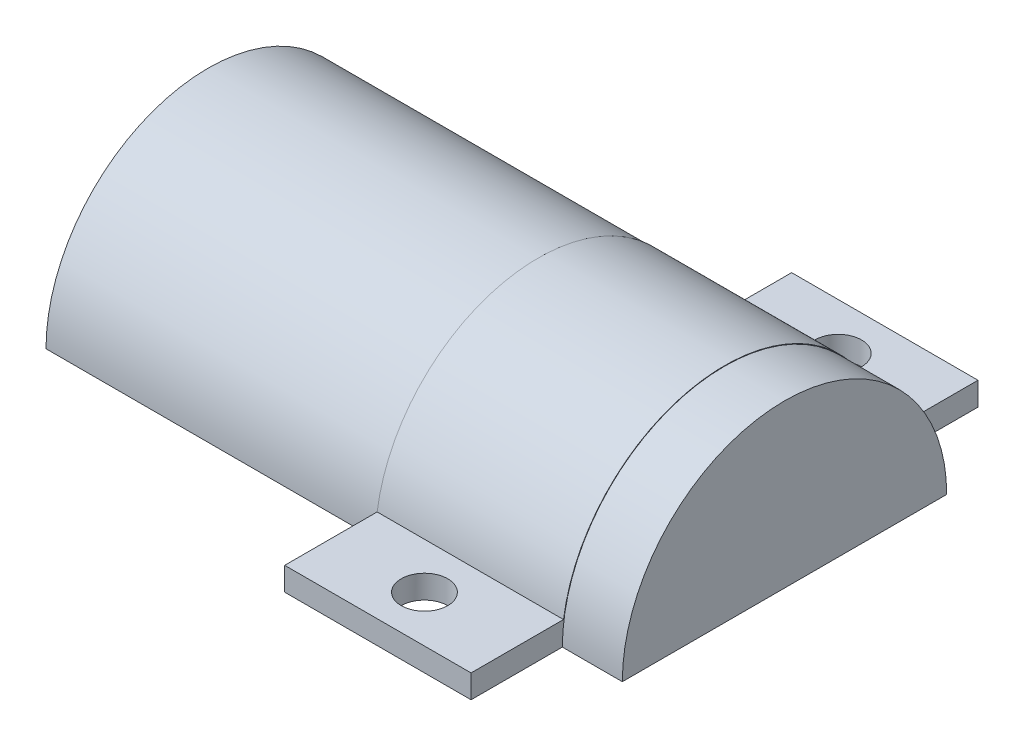
from build123d import *

# Parameters (mm, degrees)
BOSS_EXTRUDE1_DEPTH = 25.4
SKETCH2_R           = 3.175
CUT_EXTRUDE1_DEPTH  = 25.4
SKETCH3_R           = 3.175
CUT_EXTRUDE2_DEPTH  = 25.4
BOSS_EXTRUDE2_DEPTH = 5
BOSS_EXTRUDE3_DEPTH = 3.175
BOSS_EXTRUDE4_DEPTH = 45


with BuildPart() as part:
    # Sketch1 → Boss-Extrude1 (new body)
    with BuildSketch(Plane(origin=(0, 0, 0), x_dir=(0, 0, -1), z_dir=(1, 0, 0))):
        with BuildLine():
            Line((19, 0), (34.546525921, 0))
            Line((34.546525921, 0), (34.546525921, 3.175))
            Line((34.546525921, 3.175), (21.946525921, 3.175))
            ThreePointArc((21.946525921, 3.175), (0, 22.175), (-21.946525921, 3.175))
            Line((-21.946525921, 3.175), (-34.546525921, 3.175))
            Line((-34.546525921, 3.175), (-34.546525921, 0))
            Line((-34.546525921, 0), (-19, 0))
            ThreePointArc((-19, 0), (0, 19), (19, 0))
        make_face()
    extrude(amount=BOSS_EXTRUDE1_DEPTH)

    # Sketch2 → Cut-Extrude1 (cut)
    with BuildSketch(Plane(origin=(0, 3.175, 0), x_dir=(1, 0, 0), z_dir=(0, 1, 0))):
        with Locations(Location((12.7, -28.196525921, 0), (0, 0, 270))):
            Circle(SKETCH2_R)
    extrude(amount=-CUT_EXTRUDE1_DEPTH, mode=Mode.SUBTRACT)

    # Sketch3 → Cut-Extrude2 (cut)
    with BuildSketch(Plane(origin=(0, 3.175, 0), x_dir=(1, 0, 0), z_dir=(0, 1, 0))):
        with Locations(Location((12.7, 28.196525921, 0), (0, 0, 270))):
            Circle(SKETCH3_R)
    extrude(amount=-CUT_EXTRUDE2_DEPTH, mode=Mode.SUBTRACT)

    # Sketch4 → Boss-Extrude2 (add)
    with BuildSketch(Plane(origin=(25.4, 0, 0), x_dir=(0, 0, -1), z_dir=(1, 0, 0))):
        with BuildLine():
            Line((-22.104651978, 0), (-19, 0))
            ThreePointArc((-19, 0), (0, 19), (19, 0))
            Line((19, 0), (22.104651978, 0))
            ThreePointArc((22.104651978, 0), (0, 22.104651978), (-22.104651978, 0))
        make_face()
    extrude(amount=BOSS_EXTRUDE2_DEPTH)

    # Sketch5 → Boss-Extrude3 (add)
    with BuildSketch(Plane(origin=(30.4, 0, 0), x_dir=(0, 0, -1), z_dir=(1, 0, 0))):
        with BuildLine():
            ThreePointArc((22.104651978, 0), (0, 22.104651978), (-22.104651978, 0))
            Line((-22.104651978, 0), (22.104651978, 0))
        make_face()
    extrude(amount=BOSS_EXTRUDE3_DEPTH)

    # Sketch6 → Boss-Extrude4 (add)
    with BuildSketch(Plane.ZY):
        with BuildLine():
            ThreePointArc((-19, 0), (0, 19), (19, 0))
            Line((19, 0), (21.402036048, 0))
            Line((21.402036048, 0), (22.079689898, 0))
            ThreePointArc((22.079689898, 0), (0, 22.079689898), (-22.079689898, 0))
            Line((-22.079689898, 0), (-19, 0))
        make_face()
    extrude(amount=BOSS_EXTRUDE4_DEPTH)


solid = part.part
